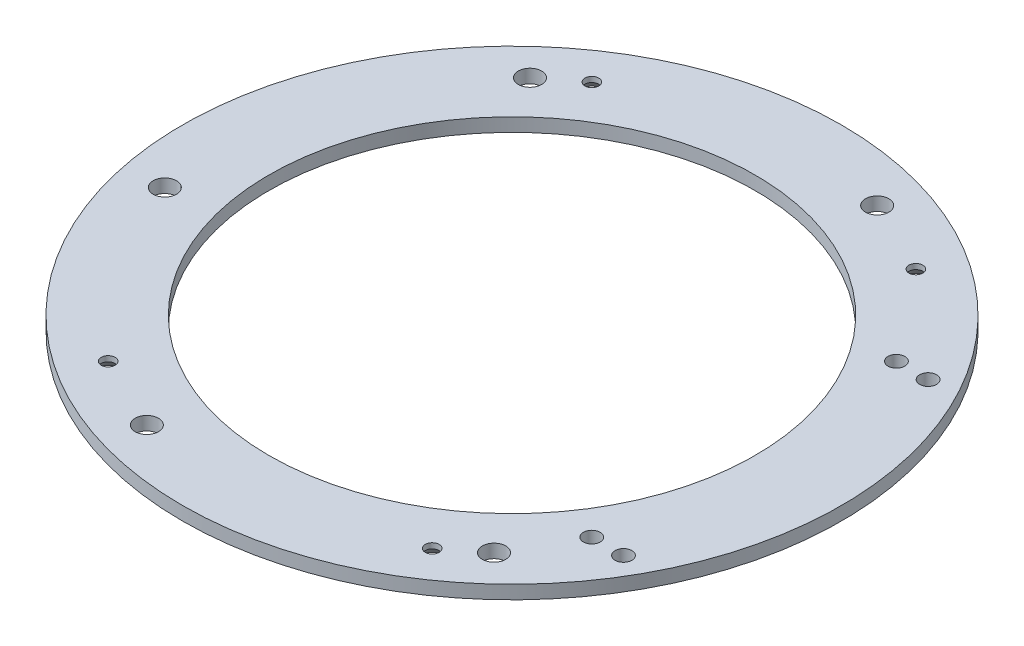
from build123d import *

# Parameters (mm, degrees)
GEMINI_SKIRT_F_2_R                            = 77.4954
GEMINI_SKIRT_F_2_R_2                          = 57.15
GEMINI_SKIRT_F_DEPTH                          = 3.175
M5_CLEARANCE_HOLE1_D                          = 5.5
M5_CLEARANCE_HOLE1_DEPTH                      = 3.175
CSK_FOR_4_FLAT_HEAD_MACHINE_SCREW1_AT_2_COUNT = 2
CSK_FOR_4_FLAT_HEAD_MACHINE_SCREW1_AT_2_PITCH = 76.2
CSK_FOR_4_FLAT_HEAD_MACHINE_SCREW1_AT_3_COUNT = 2
CSK_FOR_4_FLAT_HEAD_MACHINE_SCREW1_AT_3_PITCH = 113.740110937
CSK_FOR_4_FLAT_HEAD_MACHINE_SCREW1_AT_4_COUNT = 2
CSK_FOR_4_FLAT_HEAD_MACHINE_SCREW1_AT_4_PITCH = 136.906
F_5_32_0_15625_DIAMETER_HOLE1_D               = 3.96875
F_5_32_0_15625_DIAMETER_HOLE1_DEPTH           = 3.175


with BuildPart() as part:
    # GEMINI_SKIRT-F 2 → GEMINI_SKIRT_F (new body)
    with BuildSketch(Plane(origin=(0, -40.33266, 0), x_dir=(1, 0, 0), z_dir=(0, 1, 0))):
        Circle(GEMINI_SKIRT_F_2_R)
        Circle(GEMINI_SKIRT_F_2_R_2, mode=Mode.SUBTRACT)
    extrude(amount=-GEMINI_SKIRT_F_DEPTH)

    # M5 Clearance Hole1
    with Locations(Plane(origin=(0, -40.33266, 0), x_dir=(1, 0, 0), z_dir=(0, 1, 0))):
        with Locations((20.584214093, 65.28478643), (46.246176482, -50.468845537), (-20.584214093, -65.28478643), (-46.246176482, 50.468845537), (-66.830390575, -14.815940893)):
            Hole(M5_CLEARANCE_HOLE1_D / 2, depth=M5_CLEARANCE_HOLE1_DEPTH)

    # Sketch8 → CSK for #4 Flat Head Machine Screw1 (revolve, cut)
    with BuildSketch(Plane(origin=(38.1, -43.50766, -56.870055469), x_dir=(0, 0, -1), z_dir=(1, 0, 0))):
        Polygon((0, 0), (0, 3.175), (1.63195, 3.175), (1.63195, 1.921172758), (3.302, 0), align=None)
    csk_for_4_flat_head_machine_screw1 = revolve(axis=Axis((38.1, -49.85766, -56.870055469), (0, 1, 0)), mode=Mode.SUBTRACT)

    # CSK for #4 Flat Head Machine Screw1 at 2: CSK for #4 Flat Head Machine Screw1 ×2
    with Locations(*[(-i * CSK_FOR_4_FLAT_HEAD_MACHINE_SCREW1_AT_2_PITCH, 0, 0) for i in range(1, CSK_FOR_4_FLAT_HEAD_MACHINE_SCREW1_AT_2_COUNT)]):
        add(csk_for_4_flat_head_machine_screw1, mode=Mode.SUBTRACT)

    # CSK for #4 Flat Head Machine Screw1 at 3: CSK for #4 Flat Head Machine Screw1 ×2
    with Locations(*[(0, 0, i * CSK_FOR_4_FLAT_HEAD_MACHINE_SCREW1_AT_3_PITCH) for i in range(1, CSK_FOR_4_FLAT_HEAD_MACHINE_SCREW1_AT_3_COUNT)]):
        add(csk_for_4_flat_head_machine_screw1, mode=Mode.SUBTRACT)

    # CSK for #4 Flat Head Machine Screw1 at 4: CSK for #4 Flat Head Machine Screw1 ×2
    with Locations(*[Vector(-0.556586271, 0, 0.830789819) * (i * CSK_FOR_4_FLAT_HEAD_MACHINE_SCREW1_AT_4_PITCH) for i in range(1, CSK_FOR_4_FLAT_HEAD_MACHINE_SCREW1_AT_4_COUNT)]):
        add(csk_for_4_flat_head_machine_screw1, mode=Mode.SUBTRACT)

    # 5/32 (0.15625) Diameter Hole1
    with Locations(Plane(origin=(0, -40.33266, 0), x_dir=(1, 0, 0), z_dir=(0, 1, 0))):
        with Locations((62.031667622, -35.814), (54.576319847, -35.814), (54.576319847, 35.814), (62.031667622, 35.814)):
            Hole(F_5_32_0_15625_DIAMETER_HOLE1_D / 2, depth=F_5_32_0_15625_DIAMETER_HOLE1_DEPTH)


solid = part.part
